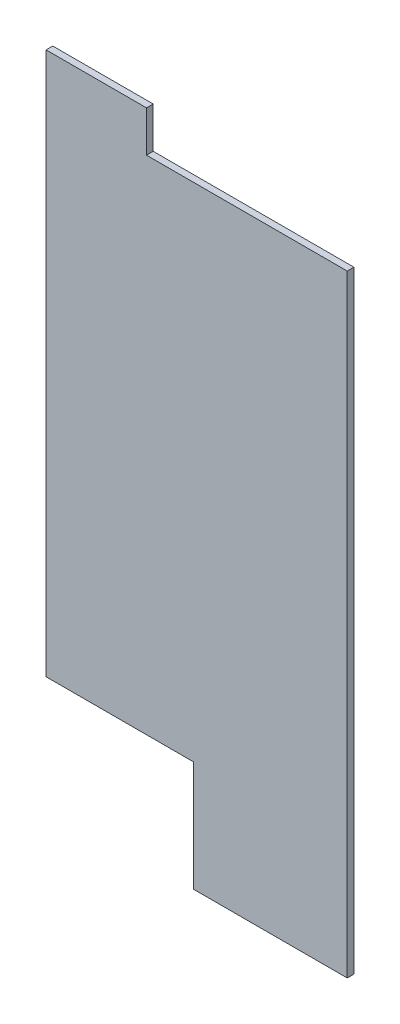
from build123d import *

# Parameters (mm, degrees)
SKETCH1_W           = 45
SKETCH1_H           = 75
BOSS_EXTRUDE1_DEPTH = 1
SKETCH2_W           = 23
SKETCH2_H           = 16.479286024
BOSS_EXTRUDE2_DEPTH = 1
SKETCH3_W           = 15.006040788
SKETCH3_H           = 6.122008564
BOSS_EXTRUDE3_DEPTH = 1


with BuildPart() as part:
    # Sketch1 → Boss-Extrude1 (new body)
    with BuildSketch(Plane.XY):
        Rectangle(SKETCH1_W, SKETCH1_H)
    extrude(amount=BOSS_EXTRUDE1_DEPTH)

    # Sketch2 → Boss-Extrude2 (add)
    with BuildSketch(Plane.XY.offset(1)):
        with Locations((11, -45.739643012)):
            Rectangle(SKETCH2_W, SKETCH2_H)
    extrude(amount=-BOSS_EXTRUDE2_DEPTH)

    # Sketch3 → Boss-Extrude3 (add)
    with BuildSketch(Plane.XY.offset(1)):
        with Locations((-14.996979606, 40.561004282)):
            Rectangle(SKETCH3_W, SKETCH3_H)
    extrude(amount=-BOSS_EXTRUDE3_DEPTH)


solid = part.part
